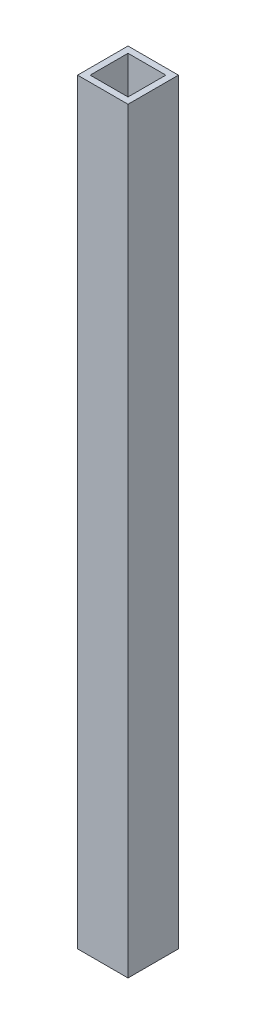
from build123d import *

# Parameters (mm, degrees)
SKETCH1_W               = 25.4
SKETCH1_H               = 25.4
BOSS_EXTRUDE1_DEPTH     = 381
SKETCH2_W               = 19.05
SKETCH2_H               = 19.05
CUT_EXTRUDE1_DEPTH      = 1
CUT_EXTRUDE1_DEPTH_BACK = 382


with BuildPart() as part:
    # Sketch1 → Boss-Extrude1 (new body)
    with BuildSketch(Plane(origin=(0, 0, 0), x_dir=(1, 0, 0), z_dir=(0, 1, 0))):
        Rectangle(SKETCH1_W, SKETCH1_H)
    extrude(amount=BOSS_EXTRUDE1_DEPTH)

    # Sketch2 → Cut-Extrude1 (cut, two sides)
    with BuildSketch(Plane(origin=(0, 381, 0), x_dir=(1, 0, 0), z_dir=(0, 1, 0))) as cut_extrude1_sk:
        Rectangle(SKETCH2_W, SKETCH2_H)
    extrude(amount=CUT_EXTRUDE1_DEPTH, mode=Mode.SUBTRACT)
    extrude(cut_extrude1_sk.sketch, amount=-CUT_EXTRUDE1_DEPTH_BACK, mode=Mode.SUBTRACT)


solid = part.part
